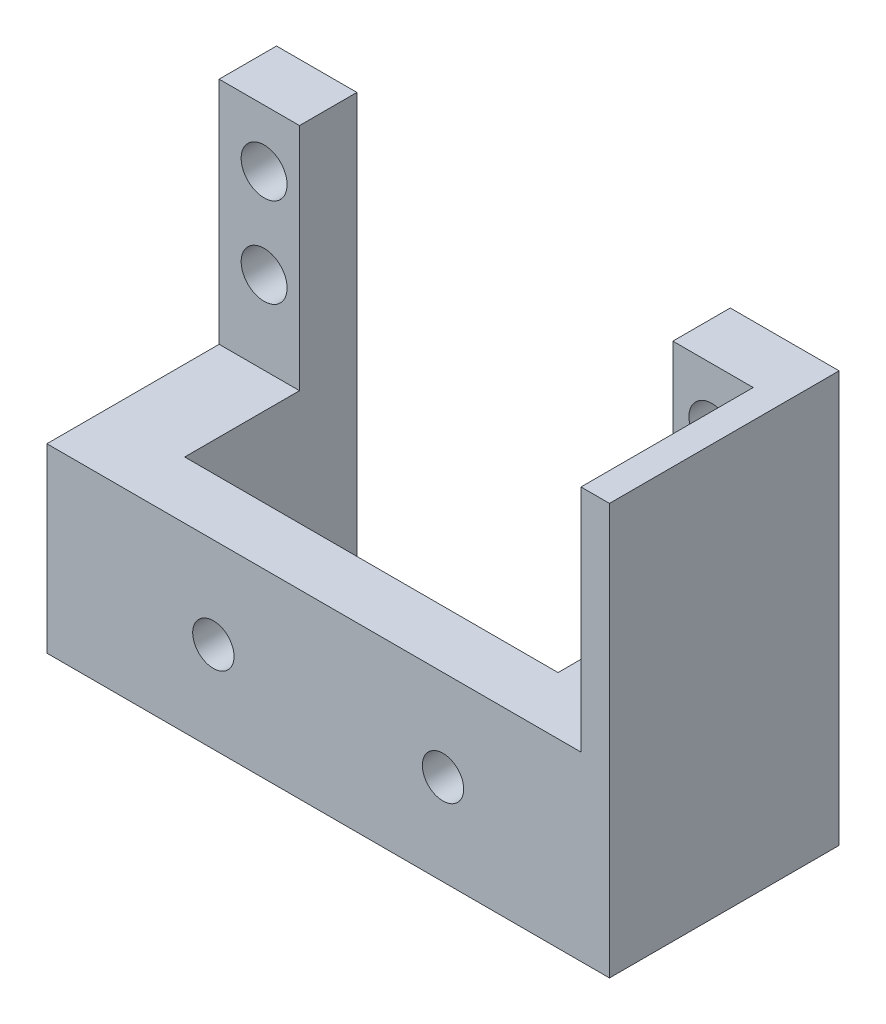
from build123d import *

# Parameters (mm, degrees)
SKETCH1_W           = 62.23
SKETCH1_H           = 20.066
BOSS_EXTRUDE1_DEPTH = 25.4
BOSS_EXTRUDE2_DEPTH = 25.4
SKETCH4_W           = 8.89
SKETCH4_H           = 6.35
BOSS_EXTRUDE3_DEPTH = 25.4
SKETCH5_R           = 2.54
CUT_EXTRUDE1_DEPTH  = 7.35
SKETCH10_W          = 41.3004
SKETCH10_H          = 20.066
CUT_EXTRUDE6_DEPTH  = 19.05
SKETCH11_R          = 2.286
CUT_EXTRUDE7_DEPTH  = 26.4


with BuildPart() as part:
    # Sketch1 → Boss-Extrude1 (new body)
    with BuildSketch(Plane.XY):
        with Locations((3812.36685564, 1.533)):
            Rectangle(SKETCH1_W, SKETCH1_H)
    extrude(amount=BOSS_EXTRUDE1_DEPTH)

    # Sketch3 → Boss-Extrude2 (add)
    with BuildSketch(Plane(origin=(0, 11.566, 0), x_dir=(1, 0, 0), z_dir=(0, 1, 0))):
        Polygon((3831.44225564, 0), (3831.44225564, -6.35), (3840.33225564, -6.35), (3840.33225564, -25.4), (3843.48185564, -25.4), (3843.48185564, 0), align=None)
    extrude(amount=BOSS_EXTRUDE2_DEPTH)

    # Sketch4 → Boss-Extrude3 (add)
    with BuildSketch(Plane(origin=(0, 11.566, 0), x_dir=(1, 0, 0), z_dir=(0, 1, 0))):
        with Locations((3785.69685564, -3.175)):
            Rectangle(SKETCH4_W, SKETCH4_H)
    extrude(amount=BOSS_EXTRUDE3_DEPTH)

    # Sketch5 → Cut-Extrude1 (cut, through all)
    with BuildSketch(Plane.XY.offset(6.35)):
        with Locations((3835.76025564, 30.616)):
            Circle(SKETCH5_R)
        with Locations((3835.76025564, 20.71)):
            Circle(SKETCH5_R)
        with Locations((3786.23025564, 20.71)):
            Circle(SKETCH5_R)
        with Locations((3786.23025564, 30.616)):
            Circle(SKETCH5_R)
    extrude(amount=-CUT_EXTRUDE1_DEPTH, mode=Mode.SUBTRACT)

    # Sketch10 → Cut-Extrude6 (cut)
    with BuildSketch(Plane(origin=(0, 0, 0), x_dir=(-1, 0, 0), z_dir=(0, 0, -1))):
        with Locations((-3810.79205564, 1.533)):
            Rectangle(SKETCH10_W, SKETCH10_H)
    extrude(amount=-CUT_EXTRUDE6_DEPTH, mode=Mode.SUBTRACT)

    # Sketch11 → Cut-Extrude7 (cut, through all)
    with BuildSketch(Plane.XY.offset(25.4)):
        with Locations((3799.66685564, 1.533)):
            Circle(SKETCH11_R)
        with Locations((3825.06685564, 1.533)):
            Circle(SKETCH11_R)
    extrude(amount=-CUT_EXTRUDE7_DEPTH, mode=Mode.SUBTRACT)


solid = part.part
